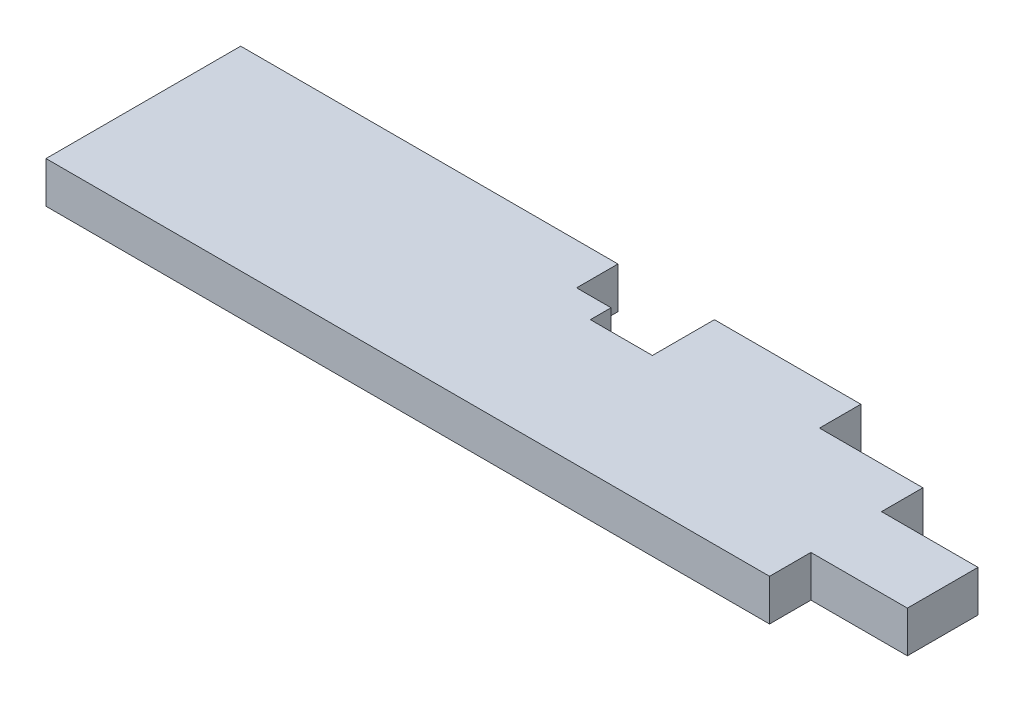
from build123d import *

# Parameters (mm, degrees)
SKETCH1_W           = 666.75
SKETCH1_H           = 179.3875
BOSS_EXTRUDE1_DEPTH = 38.1
SKETCH2_W           = 88.9
SKETCH2_H           = 141.2875
BOSS_EXTRUDE2_DEPTH = 38.1
SKETCH3_W           = 184.15
SKETCH3_H           = 38.1
CUT_EXTRUDE1_DEPTH  = 39.1
CUT_EXTRUDE2_DEPTH  = 39.1
SKETCH5_W           = 88.9
SKETCH5_H           = 38.1
CUT_EXTRUDE3_DEPTH  = 39.1


with BuildPart() as part:
    # Sketch1 → Boss-Extrude1 (new body)
    with BuildSketch(Plane(origin=(0, 0, 0), x_dir=(1, 0, 0), z_dir=(0, 1, 0))):
        with Locations((333.375, 89.69375)):
            Rectangle(SKETCH1_W, SKETCH1_H)
    extrude(amount=BOSS_EXTRUDE1_DEPTH)

    # Sketch2 → Boss-Extrude2 (add, through all)
    with BuildSketch(Plane.XZ):
        with Locations((711.2, -108.74375)):
            Rectangle(SKETCH2_W, SKETCH2_H)
    extrude(amount=-BOSS_EXTRUDE2_DEPTH)

    # Sketch3 → Cut-Extrude1 (cut, through all)
    with BuildSketch(Plane.XZ):
        with Locations((663.575, -160.3375)):
            Rectangle(SKETCH3_W, SKETCH3_H)
    extrude(amount=-CUT_EXTRUDE1_DEPTH, mode=Mode.SUBTRACT)

    # Sketch4 → Cut-Extrude2 (cut, through all)
    with BuildSketch(Plane.XZ):
        Polygon((436.55104079, -141.2875), (436.55104079, -122.2375), (379.4125, -122.2375), (379.4125, -141.2875), (347.6625, -141.2875), (347.6625, -179.3875), (436.55104079, -179.3875), align=None)
    extrude(amount=-CUT_EXTRUDE2_DEPTH, mode=Mode.SUBTRACT)

    # Sketch5 → Cut-Extrude3 (cut, through all)
    with BuildSketch(Plane.XZ):
        with Locations((711.2, -122.2375)):
            Rectangle(SKETCH5_W, SKETCH5_H)
    extrude(amount=-CUT_EXTRUDE3_DEPTH, mode=Mode.SUBTRACT)


solid = part.part
